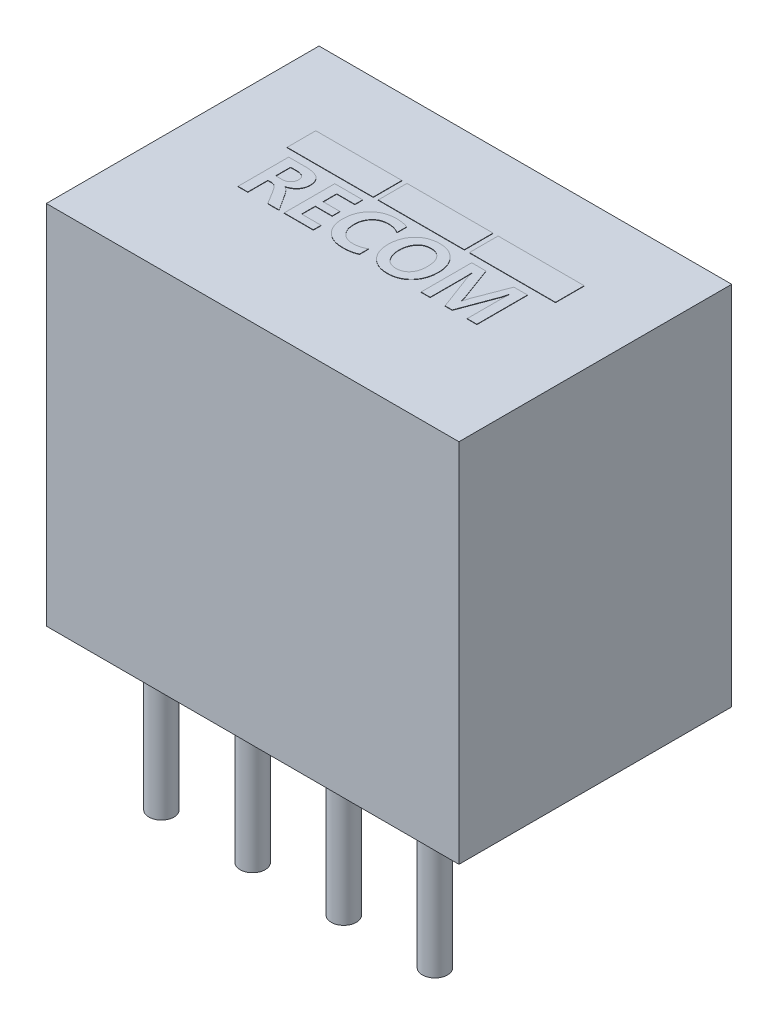
from build123d import *

# Parameters (mm, degrees)
SKETCH1_W           = 11.5
SKETCH1_H           = 7.6
BOSS_EXTRUDE1_DEPTH = 10.2
SKETCH1_3_R         = 0.35
BOSS_EXTRUDE2_DEPTH = 4.1
SKETCH2_W           = 2.4
SKETCH2_H           = 0.8
BOSS_EXTRUDE3_DEPTH = 0.01


with BuildPart() as part:
    # Sketch1 → Boss-Extrude1 (new body)
    with BuildSketch(Plane(origin=(0, 0, 0), x_dir=(1, 0, 0), z_dir=(0, 1, 0))):
        Rectangle(SKETCH1_W, SKETCH1_H)
    extrude(amount=BOSS_EXTRUDE1_DEPTH)

    # Sketch1_3 → Boss-Extrude2 (add)
    with BuildSketch(Plane(origin=(0, 0, 0), x_dir=(1, 0, 0), z_dir=(0, 1, 0))):
        with Locations((-1.27, -2.53)):
            Circle(SKETCH1_3_R)
        with Locations((-3.81, -2.53)):
            Circle(SKETCH1_3_R)
        with Locations((1.27, -2.53)):
            Circle(SKETCH1_3_R)
        with Locations((3.81, -2.53)):
            Circle(SKETCH1_3_R)
    extrude(amount=-BOSS_EXTRUDE2_DEPTH)

    # Sketch2 → Boss-Extrude3 (add)
    # profile 1 of 8: a face of its own
    with BuildSketch(Plane(origin=(0, 10.2, 0), x_dir=(1, 0, 0), z_dir=(0, 1, 0))):
        with Locations((-2.54, 1.3)):
            Rectangle(SKETCH2_W, SKETCH2_H)
    # profile 2 of 8: a face of its own
    with BuildSketch(Plane(origin=(0, 10.2, 0), x_dir=(1, 0, 0), z_dir=(0, 1, 0))):
        with Locations((0, 1.3)):
            Rectangle(SKETCH2_W, SKETCH2_H)
    # profile 3 of 8: a face of its own
    with BuildSketch(Plane(origin=(0, 10.2, 0), x_dir=(1, 0, 0), z_dir=(0, 1, 0))):
        with Locations((2.54, 1.3)):
            Rectangle(SKETCH2_W, SKETCH2_H)
    # profile 4 of 8: a face of its own
    with BuildSketch(Plane(origin=(0, 10.2, 0), x_dir=(1, 0, 0), z_dir=(0, 1, 0))):
        with BuildLine():
            Line((-2.338196915, -0.724408757), (-2.65301943, -0.724408757))
            Line((-2.65301943, -0.724408757), (-2.883342903, -0.349108668))
            add(Edge.make_bspline(
                [(-2.883342903, -0.349108668), (-2.889065834, -0.340050627), (-2.900091741, -0.322599234), (-2.916365352, -0.297671625), (-2.932259878, -0.275279056), (-2.947432976, -0.255296175), (-2.961810385, -0.237635019), (-2.975635139, -0.222577053), (-2.988971428, -0.210025145), (-3.005690975, -0.196649572), (-3.026658096, -0.183273787), (-3.053158879, -0.172174303), (-3.080505396, -0.164993724), (-3.099209874, -0.164144745), (-3.108579478, -0.163719467)],
                knots=[0, 0, 0, 0, 1.260290004, 2.42809852, 3.501063779, 4.489453867, 5.378993215, 6.178776943, 6.892148797, 7.530688844, 8.695813405, 9.803017637, 10.899469084, 12, 12, 12, 12], degree=3))
            Line((-3.108579478, -0.163719467), (-3.210882665, -0.163719467))
            Line((-3.210882665, -0.163719467), (-3.210882665, -0.724408757))
            Line((-3.210882665, -0.724408757), (-3.482183935, -0.724408757))
            Line((-3.482183935, -0.724408757), (-3.482183935, 0.686357844))
            Line((-3.482183935, 0.686357844), (-2.998645943, 0.686357844))
            add(Edge.make_bspline(
                [(-2.998645943, 0.686357844), (-2.978759066, 0.68613297), (-2.940154994, 0.685696448), (-2.884210544, 0.681017461), (-2.832042266, 0.67394387), (-2.783805556, 0.663390469), (-2.739253312, 0.650351489), (-2.698611576, 0.633840907), (-2.661689509, 0.614700878), (-2.628533661, 0.592610205), (-2.599432456, 0.567194833), (-2.57413811, 0.538831914), (-2.552755212, 0.507484911), (-2.535429386, 0.473147775), (-2.521784922, 0.435895451), (-2.51231233, 0.395572491), (-2.50662651, 0.352386367), (-2.505882034, 0.32266239), (-2.505499364, 0.307383883)],
                knots=[0, 0, 0, 0, 1.344225702, 2.609388402, 3.792916859, 4.900986039, 5.94475571, 6.927577767, 7.861970238, 8.752257416, 9.614421308, 10.467028435, 11.314960308, 12.172311822, 13.060888771, 13.990842711, 14.967267346, 16, 16, 16, 16], degree=3))
            add(Edge.make_bspline(
                [(-2.505499364, 0.307383883), (-2.505811899, 0.295977182), (-2.506425671, 0.273576056), (-2.510059685, 0.240455497), (-2.516630851, 0.20852752), (-2.525587337, 0.177659765), (-2.537395774, 0.14804604), (-2.551327957, 0.119384837), (-2.568675725, 0.092288835), (-2.587607134, 0.065874033), (-2.609560455, 0.041454545), (-2.633275923, 0.018262282), (-2.659669621, -0.002502448), (-2.688116325, -0.02157601), (-2.718701939, -0.038719896), (-2.751359485, -0.05444119), (-2.786354582, -0.067957827), (-2.810754066, -0.075239201), (-2.823147934, -0.07893782)],
                knots=[0, 0, 0, 0, 1.012628693, 1.98865752, 2.95290287, 3.90279304, 4.837546914, 5.779899327, 6.726508346, 7.689846888, 8.661316233, 9.637058477, 10.630834735, 11.637334308, 12.674488052, 13.740399365, 14.85222202, 16, 16, 16, 16], degree=3))
            Line((-2.823147934, -0.07893782), (-2.823147934, -0.082894297))
            add(Edge.make_bspline(
                [(-2.823147934, -0.082894297), (-2.814922312, -0.086129796), (-2.797504469, -0.092981001), (-2.772590452, -0.10914122), (-2.746598042, -0.129277061), (-2.720574331, -0.154728798), (-2.693508973, -0.184513059), (-2.666417911, -0.219505154), (-2.637882133, -0.258772484), (-2.619793685, -0.287297436), (-2.610346001, -0.302196156)],
                knots=[0, 0, 0, 0, 0.68144638, 1.442970127, 2.283088423, 3.220039647, 4.250693704, 5.390878668, 6.637243303, 8, 8, 8, 8], degree=3))
            Line((-2.610346001, -0.302196156), (-2.338196915, -0.724408757))
        make_face()
        with BuildLine():
            Line((-3.210882665, 0.469316829), (-3.210882665, 0.053321549))
            Line((-3.210882665, 0.053321549), (-3.044428032, 0.053321549))
            add(Edge.make_bspline(
                [(-3.044428032, 0.053321549), (-3.035184275, 0.053419179), (-3.017111369, 0.05361006), (-2.99079002, 0.057003248), (-2.965738314, 0.061535933), (-2.942334152, 0.068718406), (-2.920289009, 0.077559856), (-2.89952861, 0.088125392), (-2.880608, 0.101464691), (-2.86282623, 0.115902806), (-2.847006029, 0.132099694), (-2.833062523, 0.149401037), (-2.821173153, 0.167749575), (-2.811466768, 0.187074111), (-2.8041627, 0.207316628), (-2.79866061, 0.228385737), (-2.795585693, 0.250583939), (-2.79512334, 0.265737704), (-2.794887385, 0.273471225)],
                knots=[0, 0, 0, 0, 1.187793523, 2.322311229, 3.408112548, 4.458252248, 5.463842587, 6.460858338, 7.445431271, 8.435059429, 9.403096374, 10.350986816, 11.288524295, 12.20955774, 13.125557959, 14.05112169, 15.005416088, 16, 16, 16, 16], degree=3))
            add(Edge.make_bspline(
                [(-2.794887385, 0.273471225), (-2.79496863, 0.281400893), (-2.795126014, 0.296761949), (-2.798677501, 0.318989863), (-2.802715645, 0.339894264), (-2.809734812, 0.359098312), (-2.818544175, 0.376676888), (-2.829026622, 0.393003302), (-2.841524077, 0.407659029), (-2.855779488, 0.421007835), (-2.872460977, 0.432037572), (-2.890436375, 0.442548749), (-2.910880369, 0.450445848), (-2.932873623, 0.457690274), (-2.9569343, 0.462935406), (-2.98282602, 0.466520233), (-3.010569008, 0.468812421), (-3.029727902, 0.469145031), (-3.039623739, 0.469316829)],
                knots=[0, 0, 0, 0, 1.060683122, 2.054715356, 3.010109701, 3.908198541, 4.782933072, 5.640477322, 6.500061802, 7.357420336, 8.246509795, 9.17313587, 10.140950282, 11.174564491, 12.27366142, 13.433661261, 14.67445015, 16, 16, 16, 16], degree=3))
            Line((-3.039623739, 0.469316829), (-3.210882665, 0.469316829))
        make_face(mode=Mode.SUBTRACT)
    # profile 5 of 8: a face of its own
    with BuildSketch(Plane(origin=(0, 10.2, 0), x_dir=(1, 0, 0), z_dir=(0, 1, 0))):
        Polygon((-1.384120784, -0.724408757), (-2.198024592, -0.724408757), (-2.198024592, 0.686357844), (-1.420294286, 0.686357844), (-1.420294286, 0.469316829), (-1.926723323, 0.469316829), (-1.926723323, 0.089495051), (-1.456467789, 0.089495051), (-1.456467789, -0.127545964), (-1.926723323, -0.127545964), (-1.926723323, -0.507367742), (-1.384120784, -0.507367742), align=None)
    # profile 6 of 8: a face of its own
    with BuildSketch(Plane(origin=(0, 10.2, 0), x_dir=(1, 0, 0), z_dir=(0, 1, 0))):
        with BuildLine():
            add(Edge.make_bspline(
                [(-0.154221695, -0.665626815), (-0.167409603, -0.67187969), (-0.194284474, -0.684622059), (-0.237247822, -0.699864047), (-0.28277611, -0.71327562), (-0.331348516, -0.723862351), (-0.382650913, -0.732368187), (-0.436911282, -0.738133908), (-0.493952086, -0.741967244), (-0.533000606, -0.742316716), (-0.55297804, -0.742495509)],
                knots=[0, 0, 0, 0, 0.854610224, 1.741560423, 2.667229016, 3.634022525, 4.652059021, 5.712565366, 6.829736085, 8, 8, 8, 8], degree=3))
            add(Edge.make_bspline(
                [(-0.55297804, -0.742495509), (-0.578444379, -0.742039563), (-0.628227816, -0.741148249), (-0.70089694, -0.731643104), (-0.769826417, -0.71739551), (-0.834591519, -0.696208217), (-0.89548778, -0.669653563), (-0.952459884, -0.637003705), (-1.005140164, -0.597978701), (-1.053812492, -0.553641326), (-1.097415409, -0.504325985), (-1.135733651, -0.450846253), (-1.167658204, -0.393073821), (-1.194060871, -0.331559731), (-1.214378792, -0.266077451), (-1.229061109, -0.196757057), (-1.237943081, -0.123444467), (-1.238925247, -0.073216601), (-1.239426773, -0.047568611)],
                knots=[0, 0, 0, 0, 1.108083605, 2.166161779, 3.185316522, 4.168407951, 5.127001825, 6.073171303, 7.020584339, 7.975671295, 8.934423073, 9.881258946, 10.834097879, 11.802346283, 12.790761351, 13.813926859, 14.883719571, 16, 16, 16, 16], degree=3))
            add(Edge.make_bspline(
                [(-1.239426773, -0.047568611), (-1.2387439, -0.02060115), (-1.237404736, 0.032284041), (-1.227827469, 0.109736336), (-1.211196819, 0.183342659), (-1.188954365, 0.253450352), (-1.159017795, 0.319394577), (-1.123557197, 0.382017535), (-1.080683459, 0.440339723), (-1.032293897, 0.494819523), (-0.978660929, 0.543926423), (-0.920888807, 0.587062483), (-0.859247915, 0.623334197), (-0.794022474, 0.653153909), (-0.725030168, 0.676154145), (-0.652407343, 0.692395546), (-0.576060449, 0.702539506), (-0.523901784, 0.703801217), (-0.497304759, 0.704444596)],
                knots=[0, 0, 0, 0, 1.091637854, 2.140782853, 3.152958058, 4.143081971, 5.112656685, 6.079497617, 7.051289739, 8.037174344, 9.025070473, 9.989908742, 10.950691321, 11.914888765, 12.888094087, 13.889108241, 14.923602787, 16, 16, 16, 16], degree=3))
            add(Edge.make_bspline(
                [(-0.497304759, 0.704444596), (-0.480531854, 0.704318736), (-0.447714472, 0.704072482), (-0.399550067, 0.701063843), (-0.353413615, 0.696730846), (-0.30939758, 0.690146577), (-0.267453406, 0.682134717), (-0.227802001, 0.671788255), (-0.190018316, 0.660174569), (-0.166029253, 0.650449427), (-0.154221695, 0.645662654)],
                knots=[0, 0, 0, 0, 1.148712911, 2.247538656, 3.304355417, 4.321831148, 5.294965487, 6.227707217, 7.127667038, 8, 8, 8, 8], degree=3))
            Line((-0.154221695, 0.645662654), (-0.154221695, 0.374361384))
            add(Edge.make_bspline(
                [(-0.154221695, 0.374361384), (-0.166255433, 0.382007389), (-0.190172346, 0.397203735), (-0.228097588, 0.41634426), (-0.267043903, 0.432848986), (-0.307358642, 0.446047967), (-0.348680556, 0.456653556), (-0.391226398, 0.463831158), (-0.434927527, 0.468619231), (-0.464509425, 0.469082207), (-0.479500613, 0.469316829)],
                knots=[0, 0, 0, 0, 0.994634354, 1.976824218, 2.96110275, 3.944612288, 4.934955791, 5.935959545, 6.954008352, 8, 8, 8, 8], degree=3))
            add(Edge.make_bspline(
                [(-0.479500613, 0.469316829), (-0.496854529, 0.468879937), (-0.530839755, 0.468024346), (-0.580427905, 0.461412342), (-0.627381893, 0.450697498), (-0.671790878, 0.435739121), (-0.713486222, 0.416167602), (-0.752464496, 0.392194269), (-0.788941502, 0.364152859), (-0.822042827, 0.331499457), (-0.852272917, 0.295897538), (-0.878375597, 0.25715655), (-0.900525812, 0.21597559), (-0.918721324, 0.172149685), (-0.932780964, 0.12564865), (-0.942975177, 0.076581322), (-0.948955056, 0.024833129), (-0.949671842, -0.0105315), (-0.950038752, -0.028634043)],
                knots=[0, 0, 0, 0, 1.079563226, 2.114174171, 3.106664841, 4.072415657, 5.024280366, 5.966257424, 6.91477733, 7.880599298, 8.854022165, 9.816476437, 10.781586646, 11.759130548, 12.764126425, 13.799915638, 14.873814758, 16, 16, 16, 16], degree=3))
            add(Edge.make_bspline(
                [(-0.950038752, -0.028634043), (-0.949651597, -0.046358573), (-0.948895828, -0.080958745), (-0.94321182, -0.13155511), (-0.933611615, -0.179384435), (-0.920430116, -0.224599624), (-0.903068646, -0.2670163), (-0.881831926, -0.306685151), (-0.856833518, -0.34362367), (-0.828300711, -0.377609185), (-0.796394527, -0.408041648), (-0.761865779, -0.43474018), (-0.724712012, -0.457305465), (-0.68501653, -0.475743273), (-0.642598076, -0.48984927), (-0.59781807, -0.49990889), (-0.550529483, -0.506395062), (-0.518145332, -0.507038095), (-0.501543841, -0.507367742)],
                knots=[0, 0, 0, 0, 1.149457545, 2.243863635, 3.297126396, 4.310154787, 5.29386799, 6.26426586, 7.223423184, 8.181743352, 9.136785734, 10.077789994, 11.007238446, 11.950323152, 12.91058907, 13.900694878, 14.923807051, 16, 16, 16, 16], degree=3))
            add(Edge.make_bspline(
                [(-0.501543841, -0.507367742), (-0.485705834, -0.507129605), (-0.454340385, -0.506658002), (-0.407911723, -0.501882437), (-0.362552746, -0.49469732), (-0.318483985, -0.484154871), (-0.275481662, -0.470853155), (-0.233785928, -0.454415324), (-0.19304301, -0.435288243), (-0.167203724, -0.420062121), (-0.154221695, -0.412412297)],
                knots=[0, 0, 0, 0, 1.041829192, 2.06322929, 3.068017682, 4.061828653, 5.04211246, 6.027439535, 7.008957229, 8, 8, 8, 8], degree=3))
            Line((-0.154221695, -0.412412297), (-0.154221695, -0.665626815))
        make_face()
    # profile 7 of 8: a face of its own
    with BuildSketch(Plane(origin=(0, 10.2, 0), x_dir=(1, 0, 0), z_dir=(0, 1, 0))):
        with BuildLine():
            add(Edge.make_bspline(
                [(0.008559067, -0.036264391), (0.00914763, -0.009390296), (0.010299315, 0.043196155), (0.019563486, 0.12015096), (0.034415899, 0.193269174), (0.055196599, 0.262568956), (0.082597203, 0.327718632), (0.11579735, 0.389074338), (0.15485186, 0.446667054), (0.19981709, 0.49974578), (0.249689489, 0.547711668), (0.303879197, 0.589832423), (0.362180501, 0.6253942), (0.424529808, 0.654274088), (0.490706014, 0.677023165), (0.560902564, 0.692986727), (0.635003095, 0.702828835), (0.685744624, 0.703898056), (0.711681524, 0.704444596)],
                knots=[0, 0, 0, 0, 1.121472444, 2.194464738, 3.230121258, 4.232697178, 5.209061049, 6.174981034, 7.140164433, 8.108322752, 9.073313906, 10.02341791, 10.967522614, 11.917463873, 12.886133085, 13.882878182, 14.917817871, 16, 16, 16, 16], degree=3))
            add(Edge.make_bspline(
                [(0.711681524, 0.704444596), (0.736299187, 0.703875976), (0.784493595, 0.702762781), (0.854907703, 0.693210504), (0.921687768, 0.677781689), (0.984796788, 0.655929277), (1.044324903, 0.627874813), (1.099863602, 0.593184287), (1.151713839, 0.552366964), (1.199495273, 0.505915591), (1.242619694, 0.454568247), (1.280495499, 0.399283195), (1.312047827, 0.340205689), (1.338441147, 0.277878589), (1.358267211, 0.211863687), (1.372676491, 0.142468897), (1.381693519, 0.069573313), (1.382659062, 0.019718091), (1.383152166, -0.005742998)],
                knots=[0, 0, 0, 0, 1.075105638, 2.104752144, 3.098035666, 4.065079007, 5.016842596, 5.966985372, 6.919558332, 7.8945557, 8.873090516, 9.844511401, 10.816751425, 11.794351104, 12.796800458, 13.822689538, 14.88804632, 16, 16, 16, 16], degree=3))
            add(Edge.make_bspline(
                [(1.383152166, -0.005742998), (1.382529124, -0.032518892), (1.381310309, -0.08489878), (1.372533953, -0.161618828), (1.357545172, -0.234307828), (1.33697607, -0.303298167), (1.310058925, -0.36825856), (1.276989441, -0.429280285), (1.238612597, -0.486800449), (1.193841523, -0.539367199), (1.144685508, -0.587214782), (1.090893373, -0.628628028), (1.033445673, -0.663979243), (0.972131919, -0.692886927), (0.906939565, -0.715364257), (0.837847702, -0.730966149), (0.765005643, -0.74088898), (0.715105833, -0.741952643), (0.689638295, -0.742495509)],
                knots=[0, 0, 0, 0, 1.128167298, 2.20695811, 3.248572207, 4.251931061, 5.236048942, 6.205771933, 7.172394642, 8.14416278, 9.109855911, 10.05785514, 10.998705411, 11.94689576, 12.908468407, 13.898325424, 14.927361119, 16, 16, 16, 16], degree=3))
            add(Edge.make_bspline(
                [(0.689638295, -0.742495509), (0.664832529, -0.741926659), (0.616263374, -0.740812863), (0.545286253, -0.73126062), (0.477946889, -0.715831662), (0.414185242, -0.69395873), (0.354072903, -0.665849862), (0.29732747, -0.631817084), (0.244573757, -0.591069055), (0.19593007, -0.544543389), (0.151964745, -0.493344558), (0.113676299, -0.438156456), (0.080783033, -0.379747169), (0.054726902, -0.317493761), (0.033783076, -0.25210658), (0.019413194, -0.183149953), (0.009932928, -0.110853594), (0.009022916, -0.061447516), (0.008559067, -0.036264391)],
                knots=[0, 0, 0, 0, 1.080052709, 2.114719875, 3.11299101, 4.084866105, 5.044889684, 5.998367451, 6.961017878, 7.941936513, 8.92547754, 9.895236995, 10.863258872, 11.839498082, 12.82959871, 13.849219542, 14.903710337, 16, 16, 16, 16], degree=3))
        make_face()
        with BuildLine():
            add(Edge.make_bspline(
                [(0.297947088, -0.021003695), (0.29825022, -0.038351307), (0.298844662, -0.072369982), (0.304171112, -0.12220763), (0.312088457, -0.169696569), (0.323850028, -0.21475574), (0.338677443, -0.257479788), (0.357245875, -0.29776341), (0.378653129, -0.33584096), (0.403472991, -0.371046686), (0.431018918, -0.403063204), (0.461433796, -0.431007257), (0.494357628, -0.454479219), (0.52945894, -0.474014002), (0.567079268, -0.48901699), (0.607087382, -0.499783173), (0.649503696, -0.505984761), (0.678502455, -0.506900217), (0.693312167, -0.507367742)],
                knots=[0, 0, 0, 0, 1.182102207, 2.318102905, 3.41279402, 4.460921944, 5.488491476, 6.49126631, 7.480442375, 8.462024166, 9.42246041, 10.354133228, 11.270006271, 12.17245588, 13.085804486, 14.023476489, 14.990586372, 16, 16, 16, 16], degree=3))
            add(Edge.make_bspline(
                [(0.693312167, -0.507367742), (0.708689178, -0.50703083), (0.738728145, -0.506372674), (0.782385839, -0.499996343), (0.823468219, -0.489770657), (0.862062152, -0.4758797), (0.897739109, -0.457087425), (0.930973674, -0.434812549), (0.961497991, -0.408194232), (0.989084856, -0.377669893), (1.013701781, -0.343586926), (1.035150859, -0.306548599), (1.053339253, -0.266585813), (1.068302279, -0.223842764), (1.079886666, -0.178067475), (1.087938861, -0.129477681), (1.092789292, -0.078000267), (1.093433282, -0.042775172), (1.093764145, -0.024677566)],
                knots=[0, 0, 0, 0, 1.04008275, 2.031799996, 2.978052724, 3.901789991, 4.799963908, 5.699945926, 6.603713185, 7.533414636, 8.478313501, 9.443805081, 10.425141019, 11.445340204, 12.504473104, 13.616449264, 14.775402507, 16, 16, 16, 16], degree=3))
            add(Edge.make_bspline(
                [(1.093764145, -0.024677566), (1.093435633, -0.006014824), (1.092795724, 0.030338405), (1.087921516, 0.083302273), (1.080099211, 0.133173743), (1.069159999, 0.180101574), (1.054748054, 0.223968598), (1.037216525, 0.26485603), (1.016590599, 0.302755688), (0.992471996, 0.337223653), (0.965775117, 0.368394043), (0.936176838, 0.395594677), (0.90365305, 0.41825172), (0.868723326, 0.43710943), (0.830979271, 0.451541927), (0.790709859, 0.461967412), (0.747773987, 0.468313213), (0.718297707, 0.468976943), (0.703203359, 0.469316829)],
                knots=[0, 0, 0, 0, 1.257698234, 2.449875369, 3.581369221, 4.657836076, 5.693848385, 6.689260428, 7.652525348, 8.596578619, 9.519384408, 10.413706029, 11.297941717, 12.184203774, 13.082662672, 14.0143372, 14.983172764, 16, 16, 16, 16], degree=3))
            add(Edge.make_bspline(
                [(0.703203359, 0.469316829), (0.687823538, 0.468890255), (0.657862788, 0.468059265), (0.614193111, 0.461357661), (0.573032871, 0.450702902), (0.534245557, 0.435691572), (0.498040122, 0.416054225), (0.464657075, 0.39177544), (0.433466248, 0.363617843), (0.405449783, 0.331013454), (0.380190402, 0.295285662), (0.357967305, 0.257050716), (0.339693805, 0.216308468), (0.324266733, 0.173466031), (0.312487195, 0.128141635), (0.304072064, 0.080517527), (0.298861452, 0.030546499), (0.298256432, -0.003563409), (0.297947088, -0.021003695)],
                knots=[0, 0, 0, 0, 1.031871387, 2.010143012, 2.957922701, 3.880826205, 4.794696888, 5.71421533, 6.64524859, 7.608841036, 8.593040831, 9.578864117, 10.572060904, 11.586032239, 12.631968733, 13.71101741, 14.829650584, 16, 16, 16, 16], degree=3))
        make_face(mode=Mode.SUBTRACT)
    # profile 8 of 8: a face of its own
    with BuildSketch(Plane(origin=(0, 10.2, 0), x_dir=(1, 0, 0), z_dir=(0, 1, 0))):
        with BuildLine():
            Line((2.902439275, -0.724408757), (2.902439275, 0.155907341))
            add(Edge.make_bspline(
                [(2.902439275, 0.155907341), (2.902422745, 0.164479746), (2.902387687, 0.182661241), (2.902686764, 0.211582634), (2.90335047, 0.243702324), (2.903790926, 0.279032094), (2.904779097, 0.317556061), (2.905509395, 0.359292013), (2.906674945, 0.404226136), (2.907608812, 0.435216119), (2.908091385, 0.451230077)],
                knots=[0, 0, 0, 0, 0.696500254, 1.477230364, 2.349903411, 3.306756983, 4.34793366, 5.480935998, 6.698283018, 8, 8, 8, 8], degree=3))
            Line((2.908091385, 0.451230077), (2.902439275, 0.451230077))
            add(Edge.make_bspline(
                [(2.902439275, 0.451230077), (2.898707068, 0.432361088), (2.891800038, 0.397441086), (2.880433644, 0.349697527), (2.870046039, 0.310454055), (2.862138488, 0.287566807), (2.858635424, 0.277427702)],
                knots=[0, 0, 0, 0, 1.286433987, 2.380746357, 3.282666784, 4, 4, 4, 4], degree=3))
            Line((2.858635424, 0.277427702), (2.486443995, -0.724408757))
            Line((2.486443995, -0.724408757), (2.287489731, -0.724408757))
            Line((2.287489731, -0.724408757), (1.915015696, 0.268666931))
            add(Edge.make_bspline(
                [(1.915015696, 0.268666931), (1.913649237, 0.272419747), (1.910537747, 0.280965082), (1.906564202, 0.295686611), (1.901596393, 0.313517039), (1.896663352, 0.33478), (1.891033892, 0.359276), (1.884713248, 0.387024215), (1.878359629, 0.418068868), (1.873853991, 0.439832672), (1.871494451, 0.451230077)],
                knots=[0, 0, 0, 0, 0.51018959, 1.161725134, 1.94728856, 2.87582812, 3.950511025, 5.159663206, 6.512554521, 8, 8, 8, 8], degree=3))
            Line((1.871494451, 0.451230077), (1.864994525, 0.451230077))
            add(Edge.make_bspline(
                [(1.864994525, 0.451230077), (1.866010525, 0.424478943), (1.868088671, 0.369761714), (1.869847471, 0.286004868), (1.871505988, 0.198869761), (1.871498345, 0.13970554), (1.871494451, 0.109560041)],
                knots=[0, 0, 0, 0, 0.939968096, 1.922626911, 2.941531806, 4, 4, 4, 4], degree=3))
            Line((1.871494451, 0.109560041), (1.871494451, -0.724408757))
            Line((1.871494451, -0.724408757), (1.618279933, -0.724408757))
            Line((1.618279933, -0.724408757), (1.618279933, 0.686357844))
            Line((1.618279933, 0.686357844), (2.016188461, 0.686357844))
            Line((2.016188461, 0.686357844), (2.339206535, -0.190566988))
            add(Edge.make_bspline(
                [(2.339206535, -0.190566988), (2.345615566, -0.208119388), (2.357965055, -0.24194091), (2.372756248, -0.291940133), (2.385059703, -0.338590837), (2.390365956, -0.369037456), (2.392901578, -0.383586537)],
                knots=[0, 0, 0, 0, 1.117134628, 2.152594111, 3.117207157, 4, 4, 4, 4], degree=3))
            Line((2.392901578, -0.383586537), (2.399401504, -0.383586537))
            add(Edge.make_bspline(
                [(2.399401504, -0.383586537), (2.403165406, -0.369145853), (2.411071651, -0.338812545), (2.425444412, -0.292041819), (2.441136852, -0.24131638), (2.453090054, -0.206642702), (2.459313868, -0.18858875)],
                knots=[0, 0, 0, 0, 0.877518454, 1.843267155, 2.877028553, 4, 4, 4, 4], degree=3))
            Line((2.459313868, -0.18858875), (2.793918767, 0.686357844))
            Line((2.793918767, 0.686357844), (3.173740545, 0.686357844))
            Line((3.173740545, 0.686357844), (3.173740545, -0.724408757))
            Line((3.173740545, -0.724408757), (2.902439275, -0.724408757))
        make_face()
    extrude(amount=BOSS_EXTRUDE3_DEPTH)


solid = part.part
